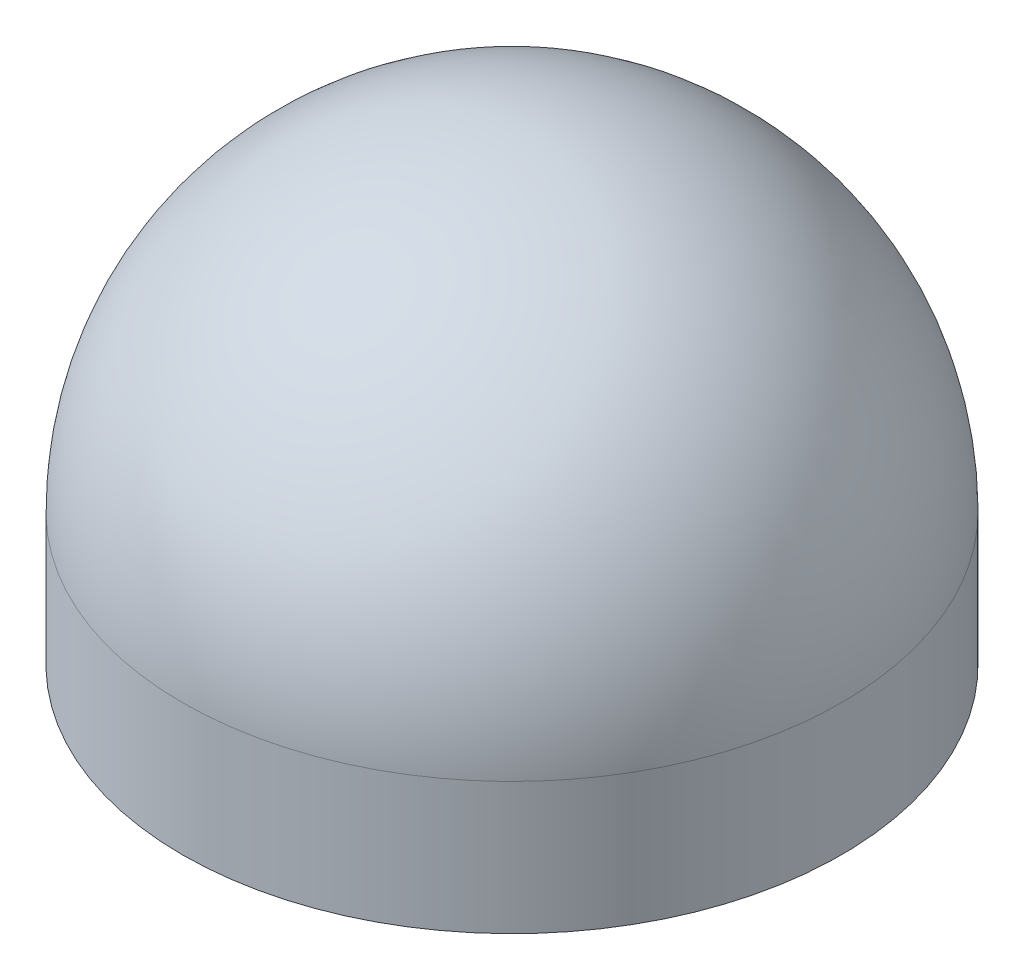
from build123d import *

# Parameters (mm, degrees)
SKETCH1_R           = 5
BOSS_EXTRUDE1_DEPTH = 7
FILLET1_R           = 5
SKETCH2_R           = 1.75
CUT_EXTRUDE1_DEPTH  = 4


with BuildPart() as part:
    # Sketch1 → Boss-Extrude1 (new body)
    with BuildSketch(Plane(origin=(0, 0, 0), x_dir=(1, 0, 0), z_dir=(0, 1, 0))):
        Circle(SKETCH1_R)
    extrude(amount=BOSS_EXTRUDE1_DEPTH)

    # Fillet1
    fillet1_edges = [part.edges().sort_by_distance(p)[0] for p in [
        (-5, 7, 0),
    ]]
    fillet(fillet1_edges, radius=FILLET1_R)

    # Sketch2 → Cut-Extrude1 (cut)
    with BuildSketch(Plane.XZ):
        Circle(SKETCH2_R)
    extrude(amount=-CUT_EXTRUDE1_DEPTH, mode=Mode.SUBTRACT)


solid = part.part
